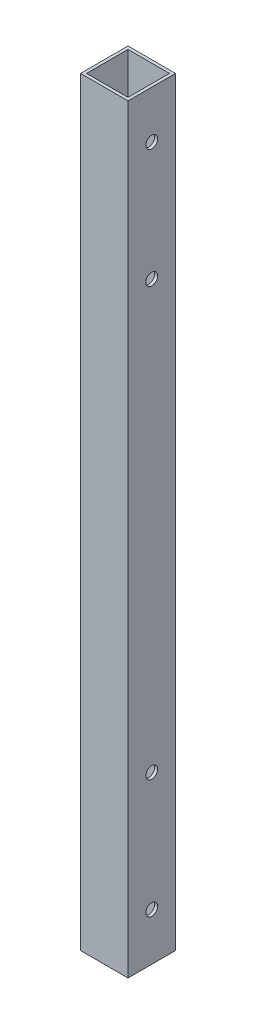
from build123d import *

# Parameters (mm, degrees)
SKETCH1_W           = 50.8
SKETCH1_H           = 50.8
SKETCH1_W_2         = 44.416753927
SKETCH1_H_2         = 44.416753927
BOSS_EXTRUDE1_DEPTH = 812.8
SKETCH2_R           = 6.35
CUT_EXTRUDE1_DEPTH  = 51.8


with BuildPart() as part:
    # Sketch1 → Boss-Extrude1 (new body)
    with BuildSketch(Plane(origin=(0, 0, 0), x_dir=(1, 0, 0), z_dir=(0, 1, 0))):
        Rectangle(SKETCH1_W, SKETCH1_H)
        with Locations((-0.016623037, 0.016623037)):
            Rectangle(SKETCH1_W_2, SKETCH1_H_2, mode=Mode.SUBTRACT)
    extrude(amount=BOSS_EXTRUDE1_DEPTH)

    # Sketch2 → Cut-Extrude1 (cut, through all)
    with BuildSketch(Plane.ZY.offset(25.4)):
        with Locations((0, 50.8)):
            Circle(SKETCH2_R)
        with Locations((0, 177.8)):
            Circle(SKETCH2_R)
        with Locations((0, 635)):
            Circle(SKETCH2_R)
        with Locations((0, 762)):
            Circle(SKETCH2_R)
    extrude(amount=-CUT_EXTRUDE1_DEPTH, mode=Mode.SUBTRACT)


solid = part.part
